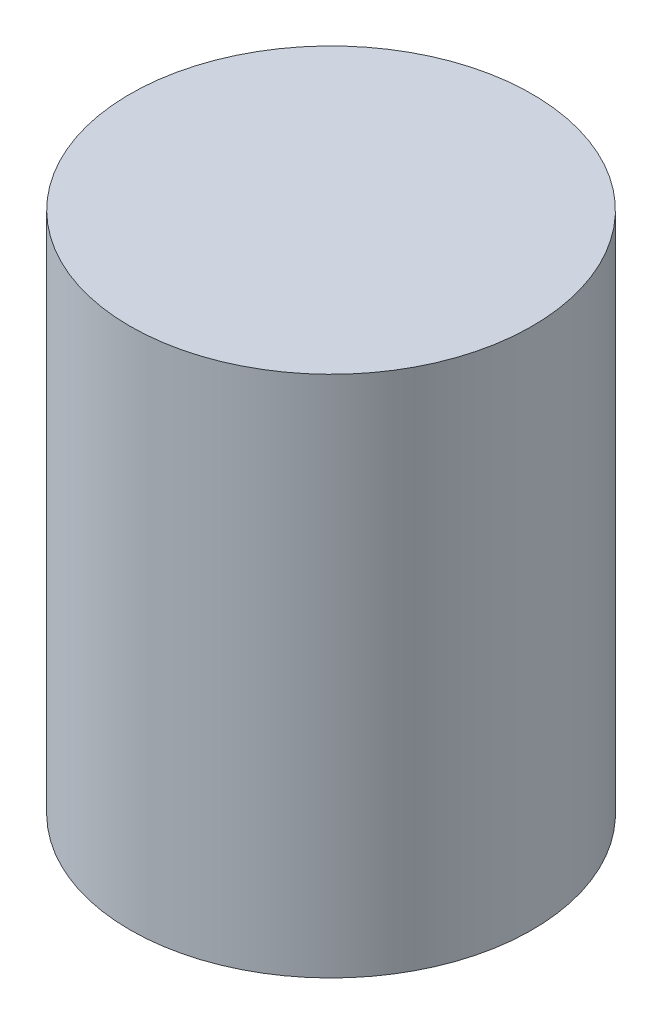
from build123d import *

# Parameters (mm, degrees)
SKETCH1_R           = 15
BOSS_EXTRUDE1_DEPTH = 39


with BuildPart() as part:
    # Sketch1 → Boss-Extrude1 (new body)
    with BuildSketch(Plane(origin=(0, 34.901980518, 0), x_dir=(1, 0, 0), z_dir=(0, 1, 0))):
        with Locations((-13.679845786, -47.798220112)):
            Circle(SKETCH1_R)
    extrude(amount=-BOSS_EXTRUDE1_DEPTH)


solid = part.part
